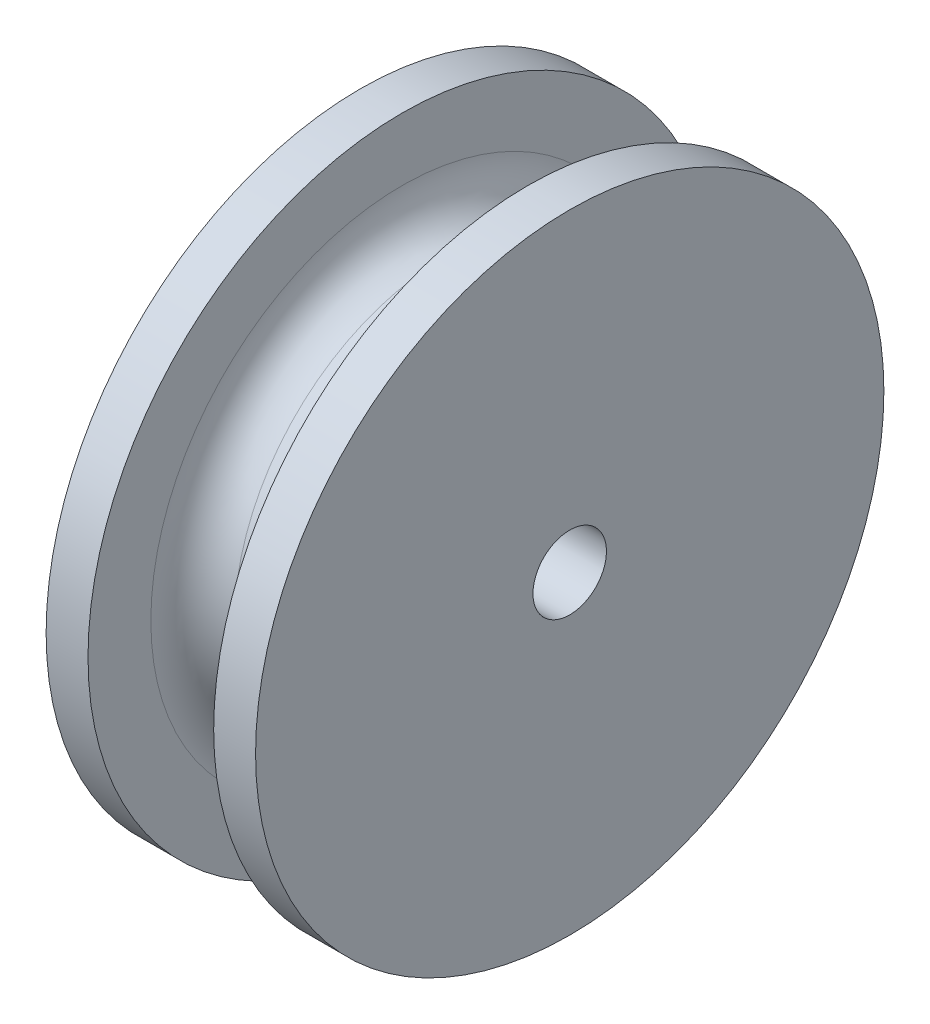
from build123d import *


with BuildPart() as part:
    # Sketch1 → Revolve1 (revolve)
    with BuildSketch(Plane.XY):
        with BuildLine():
            Line((-1, 10), (1, 10))
            ThreePointArc((1, 10), (2.414213562, 10.585786438), (3, 12))
            Line((3, 12), (3, 15))
            Line((3, 15), (5, 15))
            Line((5, 15), (5, 1.753554502))
            Line((5, 1.753554502), (-5, 1.753554502))
            Line((-5, 1.753554502), (-5, 15))
            Line((-5, 15), (-3, 15))
            Line((-3, 15), (-3, 12))
            ThreePointArc((-3, 12), (-2.414213562, 10.585786438), (-1, 10))
        make_face()
    revolve(axis=Axis((-9.241706161, 0, 0), (1, 0, 0)))


solid = part.part
